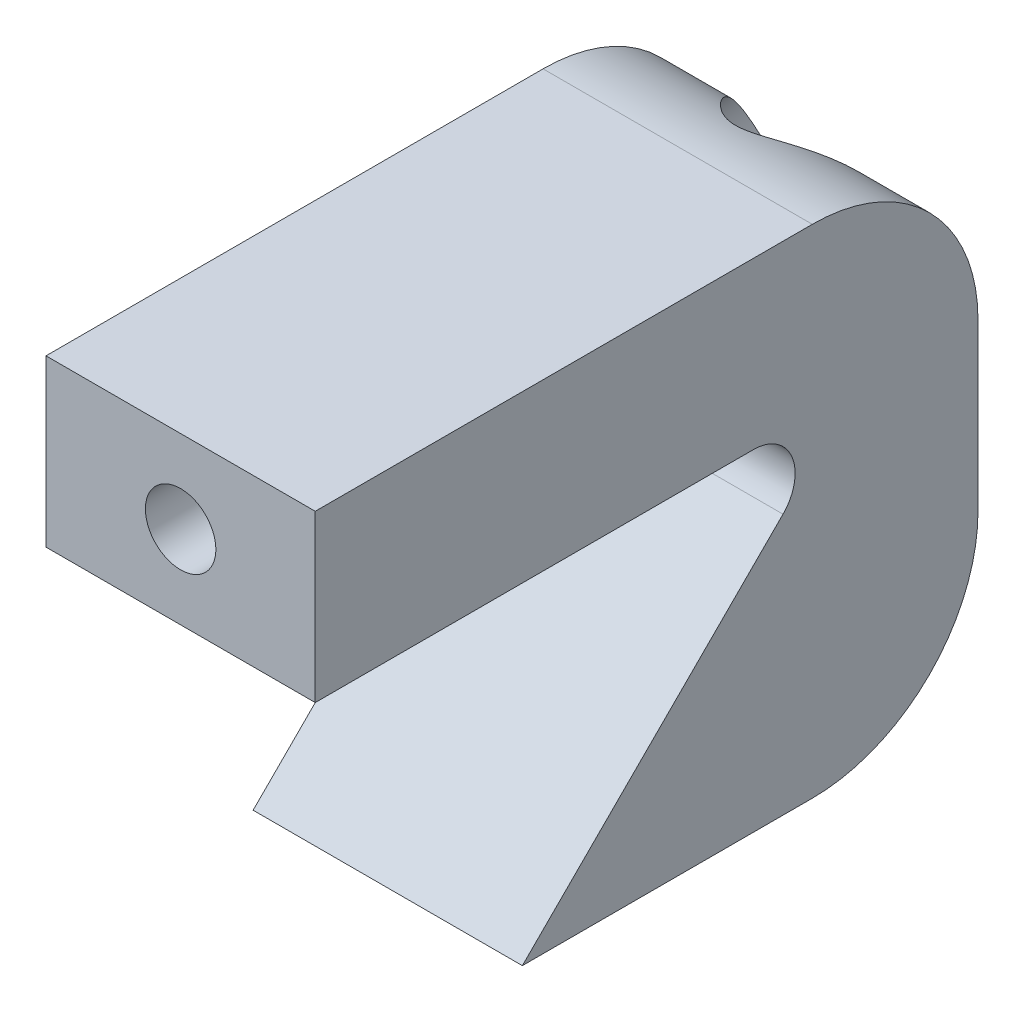
from build123d import *

# Parameters (mm, degrees)
BOSS_EXTRUDE1_DEPTH                                 = 13
FILLET2_R                                           = 8
SKETCH2_R                                           = 1.7
CUT_EXTRUDE1_DEPTH                                  = 41
SKETCH3_R                                           = 3.5
CUT_EXTRUDE2_DEPTH                                  = 28
CSK_FOR_M3_COUNTERSUNK_FLAT_HEAD_SCREW1_D           = 3.2
CSK_FOR_M3_COUNTERSUNK_FLAT_HEAD_SCREW1_CSINK_D     = 6.3
CSK_FOR_M3_COUNTERSUNK_FLAT_HEAD_SCREW1_CSINK_ANGLE = 90
FILLET3_R                                           = 2


with BuildPart() as part:
    # Sketch1 → Boss-Extrude1 (new body)
    with BuildSketch(Plane(origin=(0, 0, 0), x_dir=(0, 0, -1), z_dir=(1, 0, 0))):
        Polygon((0, -16), (-16, -16), (0, 0), (-26, 0), (-26, 8), (6, 8), (6, -16), align=None)
    extrude(amount=BOSS_EXTRUDE1_DEPTH)

    # Fillet2
    fillet2_edges = [part.edges().sort_by_distance(p)[0] for p in [
        (6.5, 8, -6),
        (6.5, -16, -6),
    ]]
    fillet(fillet2_edges, radius=FILLET2_R)

    # Sketch2 → Cut-Extrude1 (cut)
    with BuildSketch(Plane(origin=(0, 0, -6), x_dir=(-1, 0, 0), z_dir=(0, 0, -1))):
        with Locations((-6.5, 4)):
            Circle(SKETCH2_R)
    extrude(amount=-CUT_EXTRUDE1_DEPTH, mode=Mode.SUBTRACT)

    # Sketch3 → Cut-Extrude2 (cut)
    with BuildSketch(Plane(origin=(0, 0, -6), x_dir=(-1, 0, 0), z_dir=(0, 0, -1))):
        with Locations((-6.5, 4)):
            Circle(SKETCH3_R)
    extrude(amount=-CUT_EXTRUDE2_DEPTH, mode=Mode.SUBTRACT)

    # CSK for M3 Countersunk Flat Head Screw1 (through all)
    with Locations(Plane(origin=(0, 0, 22), x_dir=(-1, 0, 0), z_dir=(0, 0, -1))):
        with Locations((-6.5, 4)):
            CounterSinkHole(CSK_FOR_M3_COUNTERSUNK_FLAT_HEAD_SCREW1_D / 2, CSK_FOR_M3_COUNTERSUNK_FLAT_HEAD_SCREW1_CSINK_D / 2, counter_sink_angle=CSK_FOR_M3_COUNTERSUNK_FLAT_HEAD_SCREW1_CSINK_ANGLE)

    # Fillet3
    fillet3_edges = [part.edges().sort_by_distance(p)[0] for p in [
        (6.5, 0, 0),
    ]]
    fillet(fillet3_edges, radius=FILLET3_R)


solid = part.part
